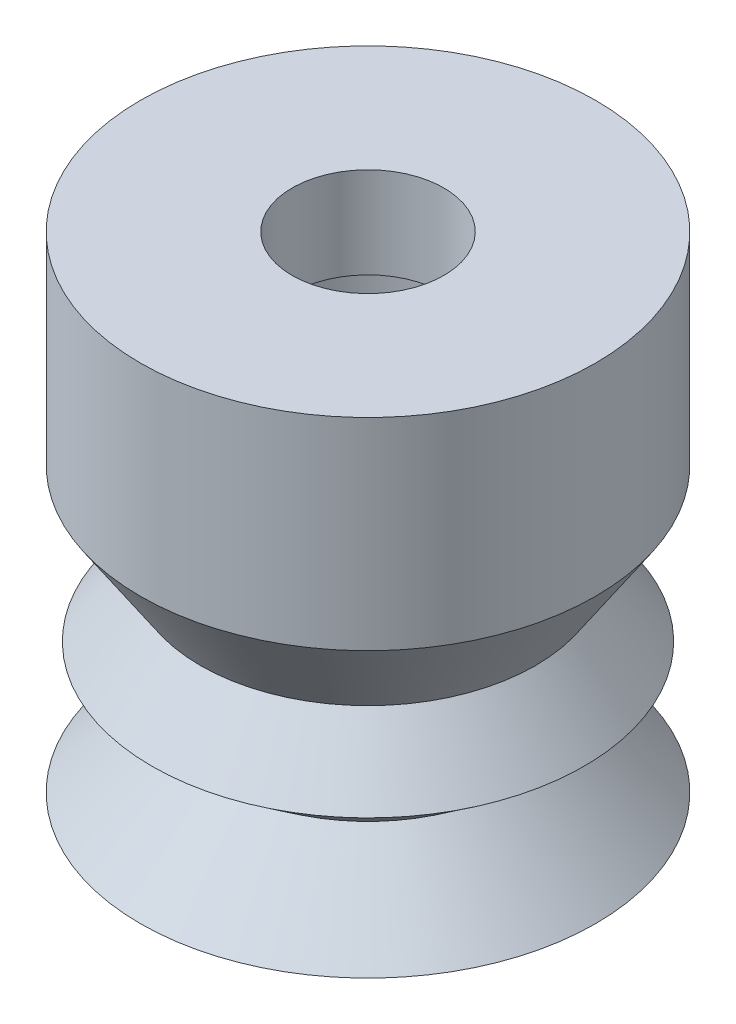
from build123d import *


with BuildPart() as part:
    # Esquisse1 → Révolution1 (revolve)
    with BuildSketch(Plane.XY):
        Polygon((-2.5, 0), (-2.5, -3), (-3.5, -3), (-3.5, -5), (-2, -5), (-2, -9.625570175), (-5.795635523, -11.694664415), (-3.5, -13.389351126), (-7.5, -16), (-4.86946953, -13.389351126), (-7.122318329, -11.694664415), (-5.518795323, -9.625570175), (-7.5, -6.656297472), (-7.5, 0), align=None)
    revolve(axis=Axis((0, 0, 0), (0, -1, 0)))


solid = part.part
